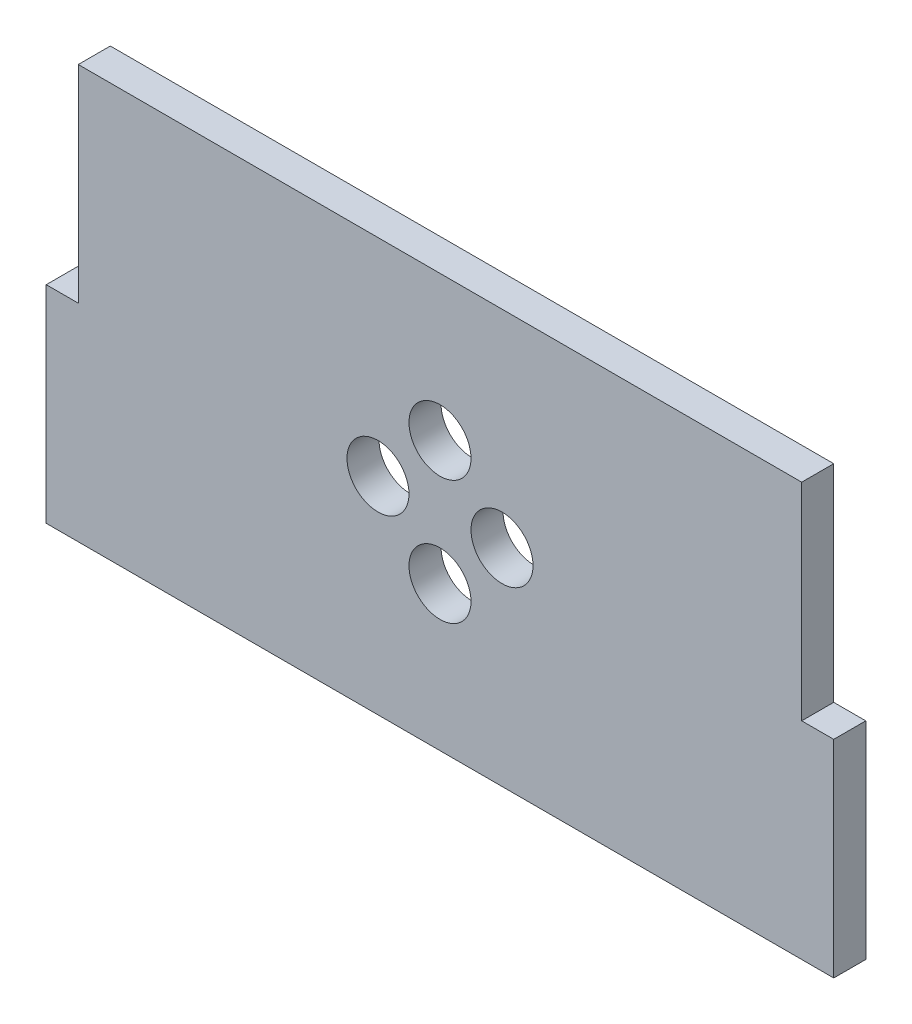
from build123d import *

# Parameters (mm, degrees)
SKETCH1_W           = 70
SKETCH1_H           = 40
SKETCH1_R           = 3
BOSS_EXTRUDE1_DEPTH = 3.1
SKETCH2_W           = 3.1
SKETCH2_H           = 20
BOSS_EXTRUDE2_DEPTH = 3.1


with BuildPart() as part:
    # Sketch1 → Boss-Extrude1 (new body)
    with BuildSketch(Plane.XY):
        Rectangle(SKETCH1_W, SKETCH1_H)
        with Locations((-6, 0)):
            Circle(SKETCH1_R, mode=Mode.SUBTRACT)
        with Locations((0, 6)):
            Circle(SKETCH1_R, mode=Mode.SUBTRACT)
        with Locations((6, 0)):
            Circle(SKETCH1_R, mode=Mode.SUBTRACT)
        with Locations((0, -6)):
            Circle(SKETCH1_R, mode=Mode.SUBTRACT)
    extrude(amount=BOSS_EXTRUDE1_DEPTH)

    # Sketch2 → Boss-Extrude2 (add, through all)
    with BuildSketch(Plane.XY.offset(3.1)):
        with Locations((36.55, -10)):
            Rectangle(SKETCH2_W, SKETCH2_H)
        with Locations((-36.55, -10)):
            Rectangle(SKETCH2_W, SKETCH2_H)
    extrude(amount=-BOSS_EXTRUDE2_DEPTH)


solid = part.part
